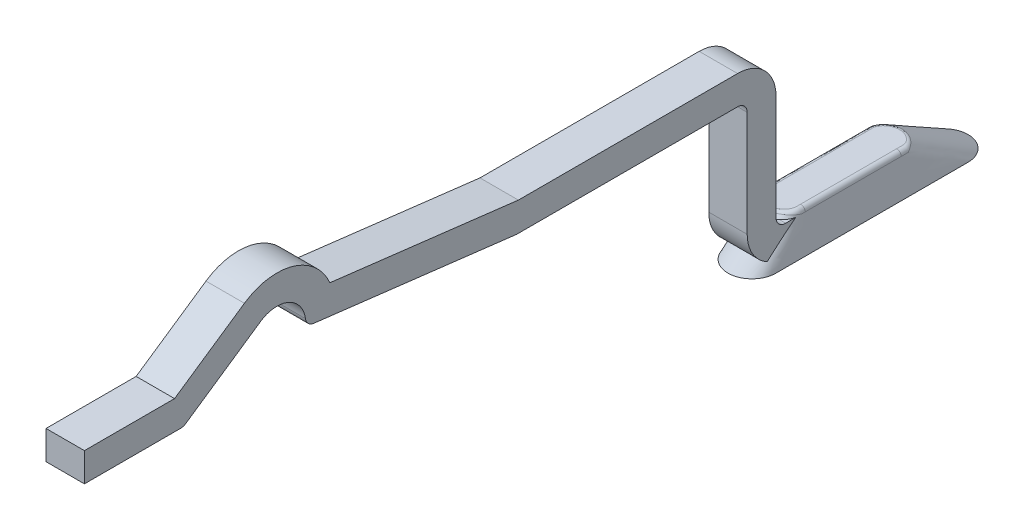
from build123d import *

# Parameters (mm, degrees)
EXTRUDE_THIN1_DEPTH = 0.2
FILLET2_R           = 0.05


with BuildPart() as part:
    # Sketch1 → Extrude-Thin1 (new body, symmetric)
    with BuildSketch(Plane(origin=(0, 0, 0), x_dir=(0, 0, -1), z_dir=(1, 0, 0))):
        with BuildLine():
            Line((1.5, 0), (0.4, 0))
            ThreePointArc((0.4, 0), (0.117157288, 0.117157288), (0, 0.4))
            Line((0, 0.4), (0, 1.5))
            ThreePointArc((0, 1.5), (-0.029289322, 1.570710678), (-0.1, 1.6))
            Line((-0.1, 1.6), (-2.4, 1.6))
            Line((-2.4, 1.6), (-4.511931163, 1.853790806))
            ThreePointArc((-4.511931163, 1.853790806), (-4.570232229, 1.88189058), (-4.599115742, 1.939807369))
            ThreePointArc((-4.599115742, 1.939807369), (-4.774219375, 2.173964421), (-5.065441937, 2.147883256))
            Line((-5.065441937, 2.147883256), (-5.843673678, 1.617372248))
            ThreePointArc((-5.843673678, 1.617372248), (-5.870527769, 1.604441706), (-5.9, 1.6))
            Line((-5.9, 1.6), (-6.9, 1.6))
            Line((-6.9, 1.6), (-6.9, 1.9))
            Line((-6.9, 1.9), (-5.961684297, 1.9))
            Line((-5.961684297, 1.9), (-5.234420904, 2.395766512))
            ThreePointArc((-5.234420904, 2.395766512), (-4.728210685, 2.475926357), (-4.344765926, 2.135860917))
            Line((-4.344765926, 2.135860917), (-2.382039107, 1.9))
            Line((-2.382039107, 1.9), (-0.1, 1.9))
            ThreePointArc((-0.1, 1.9), (0.182842712, 1.782842712), (0.3, 1.5))
            Line((0.3, 1.5), (0.3, 0.4))
            ThreePointArc((0.3, 0.4), (0.329289322, 0.329289322), (0.4, 0.3))
            Line((0.4, 0.3), (1.5, 0.3))
            Line((1.5, 0.3), (1.5, 0))
        make_face()
    extrude(amount=EXTRUDE_THIN1_DEPTH, both=True)

    # Sketch3 → Loft1 section 0
    with BuildSketch(Plane(origin=(0, 0.35, 0), x_dir=(1, 0, 0), z_dir=(0, 1, 0))):
        with BuildLine():
            Line((0.2, 1.6), (0.2, 0.6))
            ThreePointArc((0.2, 0.6), (0, 0.4), (-0.2, 0.6))
            Line((-0.2, 0.6), (-0.2, 1.6))
            ThreePointArc((-0.2, 1.6), (0, 1.8), (0.2, 1.6))
        make_face()
    # Sketch2 → Loft1 section 1
    with BuildSketch(Plane(origin=(0, -0.05, 0), x_dir=(1, 0, 0), z_dir=(0, 1, 0))):
        with BuildLine():
            Line((0.25, 2.25), (0.25, 0.25))
            ThreePointArc((0.25, 0.25), (0, 0), (-0.25, 0.25))
            Line((-0.25, 0.25), (-0.25, 2.25))
            ThreePointArc((-0.25, 2.25), (0, 2.5), (0.25, 2.25))
        make_face()
    loft()

    # Fillet2
    fillet2_edges = [part.edges().sort_by_distance(p)[0] for p in [
        (0, 0.35, -1.8),
        (-0.2, 0.35, -1.1),
        (0, 0.35, -0.4),
        (0.2, 0.35, -1.1),
    ]]
    fillet(fillet2_edges, radius=FILLET2_R)


solid = part.part
